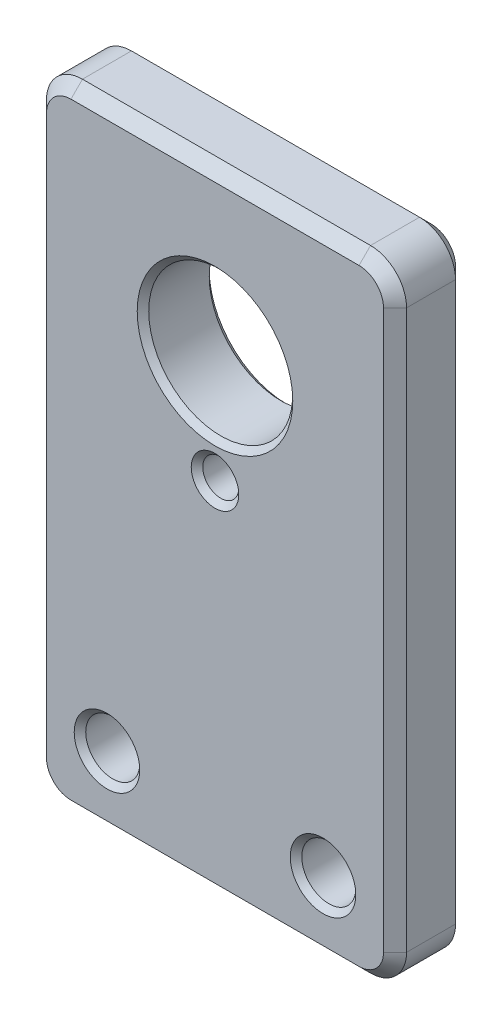
from build123d import *

# Parameters (mm, degrees)
SKETCH1_W                       = 15.875
SKETCH1_H                       = 27.78125
BOSS_EXTRUDE1_DEPTH             = 1.5875
F_3_32_0_09375_DIAMETER_HOLE1_D = 2.38125
F_1_4_0_25_DIAMETER_HOLE1_D     = 6.35
F_1_16_0_0625_DIAMETER_HOLE1_D  = 1.5875
FILLET1_R                       = 1.5875
CHAMFER1_SIZE                   = 0.508
CHAMFER2_SIZE                   = 0.254


with BuildPart() as part:
    # Sketch1 → Boss-Extrude1 (new body, symmetric)
    with BuildSketch(Plane.XY):
        Rectangle(SKETCH1_W, SKETCH1_H)
    extrude(amount=BOSS_EXTRUDE1_DEPTH, both=True)

    # 3/32 (0.09375) Diameter Hole1 (through all)
    with Locations(Plane.XY.offset(1.5875)):
        with Locations((-4.7625, -10.715625), (4.7625, -10.715625)):
            Hole(F_3_32_0_09375_DIAMETER_HOLE1_D / 2)

    # 1/4 (0.25) Diameter Hole1 (through all)
    with Locations(Plane.XY.offset(1.5875)):
        with Locations((0, 6.746875)):
            Hole(F_1_4_0_25_DIAMETER_HOLE1_D / 2)

    # 1/16 (0.0625) Diameter Hole1 (through all)
    with Locations(Plane.XY.offset(1.5875)):
        with Locations((0, 1.984375)):
            Hole(F_1_16_0_0625_DIAMETER_HOLE1_D / 2)

    # Fillet1
    fillet1_edges = [part.edges().sort_by_distance(p)[0] for p in [
        (-7.9375, -13.890625, 0),
        (7.9375, -13.890625, 0),
        (7.9375, 13.890625, 0),
        (-7.9375, 13.890625, 0),
    ]]
    fillet(fillet1_edges, radius=FILLET1_R)

    # Chamfer1
    chamfer1_edges = [part.edges().sort_by_distance(p)[0] for p in [
        (7.9375, 0, -1.5875),
        (7.9375, 0, 1.5875),
        (-7.9375, 0, -1.5875),
        (0, 13.890625, -1.5875),
        (0, -13.890625, -1.5875),
        (7.472532015, 13.425657015, -1.5875),
        (-7.472532015, 13.425657015, -1.5875),
        (-7.472532015, -13.425657015, -1.5875),
        (7.472532015, -13.425657015, -1.5875),
        (0, -13.890625, 1.5875),
        (-7.9375, 0, 1.5875),
        (0, 13.890625, 1.5875),
        (7.472532015, 13.425657015, 1.5875),
        (-7.472532015, 13.425657015, 1.5875),
        (-7.472532015, -13.425657015, 1.5875),
        (7.472532015, -13.425657015, 1.5875),
    ]]
    chamfer(chamfer1_edges, length=CHAMFER1_SIZE)

    # Chamfer2
    chamfer2_edges = [part.edges().sort_by_distance(p)[0] for p in [
        (5.953125, -10.715625, 1.5875),
        (5.953125, -10.715625, -1.5875),
        (-3.571875, -10.715625, 1.5875),
        (-3.571875, -10.715625, -1.5875),
        (3.175, 6.746875, 1.5875),
        (3.175, 6.746875, -1.5875),
        (0.79375, 1.984375, 1.5875),
        (0.79375, 1.984375, -1.5875),
    ]]
    chamfer(chamfer2_edges, length=CHAMFER2_SIZE)


solid = part.part
